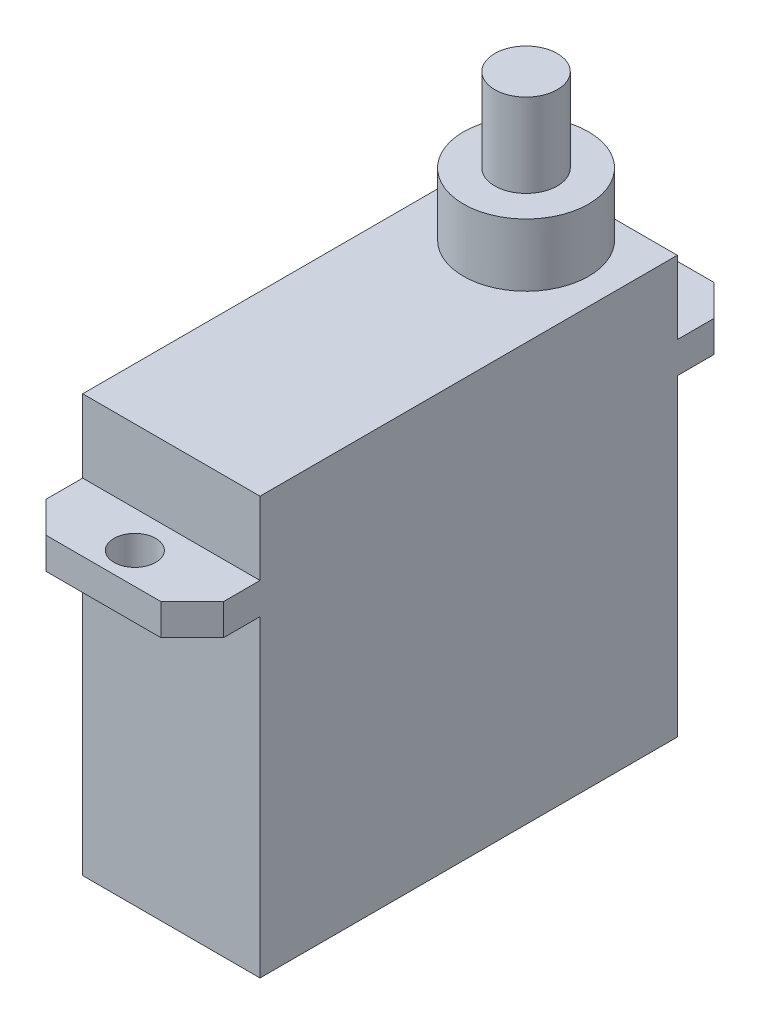
from build123d import *

# Parameters (mm, degrees)
SKETCH1_W           = 8.5
SKETCH1_H           = 20
BOSS_EXTRUDE1_DEPTH = 20
SKETCH4_R           = 1
BOSS_EXTRUDE2_DEPTH = 1.5
SKETCH6_R           = 3
BOSS_EXTRUDE3_DEPTH = 3
SKETCH7_R           = 1.5
BOSS_EXTRUDE4_DEPTH = 4


with BuildPart() as part:
    # Sketch1 → Boss-Extrude1 (new body)
    with BuildSketch(Plane(origin=(0, 0, 0), x_dir=(1, 0, 0), z_dir=(0, 1, 0))):
        Rectangle(SKETCH1_W, SKETCH1_H)
    extrude(amount=BOSS_EXTRUDE1_DEPTH)

    # Sketch4 → Boss-Extrude2 (add)
    with BuildSketch(Plane(origin=(0, 15, 0), x_dir=(1, 0, 0), z_dir=(0, 1, 0))):
        Polygon((-4.25, 10), (4.25, 10), (4.25, 11.75), (2.75, 13.25), (-2.75, 13.25), (-4.25, 11.75), align=None)
        with Locations((0, 11.75)):
            Circle(SKETCH4_R, mode=Mode.SUBTRACT)
        Polygon((-2.75, -13.25), (2.75, -13.25), (4.25, -11.75), (4.25, -10), (-4.25, -10), (-4.25, -11.75), align=None)
        with Locations((0, -11.75)):
            Circle(SKETCH4_R, mode=Mode.SUBTRACT)
    extrude(amount=BOSS_EXTRUDE2_DEPTH)

    # Sketch6 → Boss-Extrude3 (add)
    with BuildSketch(Plane(origin=(0, 20, 0), x_dir=(1, 0, 0), z_dir=(0, 1, 0))):
        with Locations((0, 7)):
            Circle(SKETCH6_R)
    extrude(amount=BOSS_EXTRUDE3_DEPTH)

    # Sketch7 → Boss-Extrude4 (add)
    with BuildSketch(Plane(origin=(0, 23, 0), x_dir=(1, 0, 0), z_dir=(0, 1, 0))):
        with Locations((0, 7)):
            Circle(SKETCH7_R)
    extrude(amount=BOSS_EXTRUDE4_DEPTH)


solid = part.part
